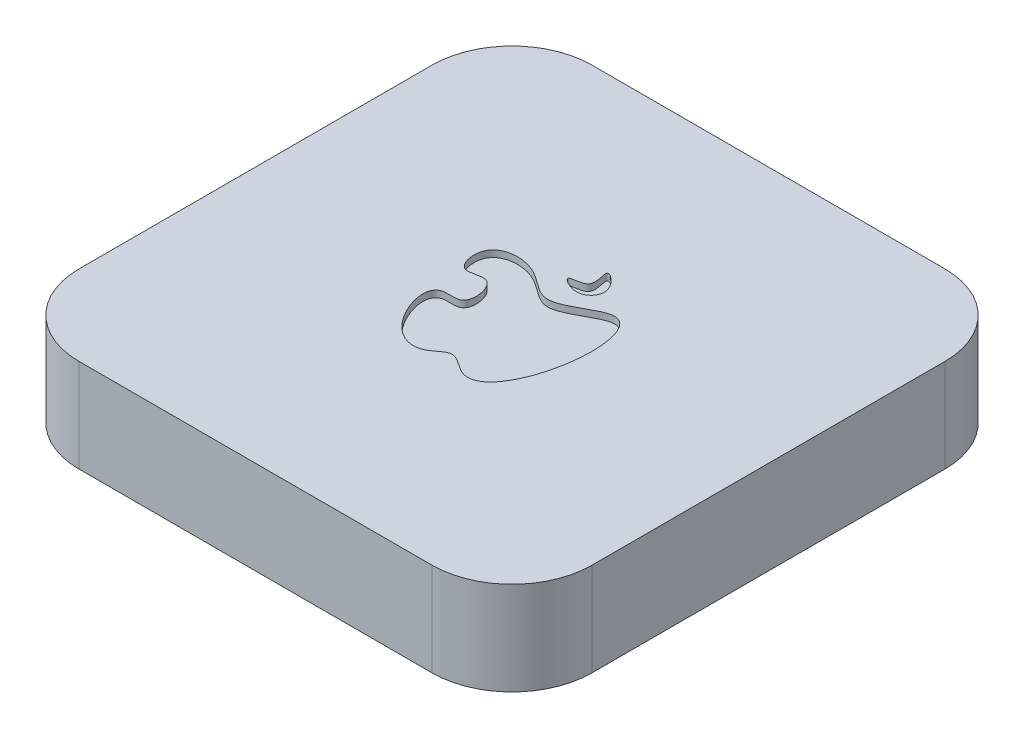
from build123d import *

# Parameters (mm, degrees)
BOSS_EXTRUDE1_DEPTH = 35.56
CUT_EXTRUDE1_DEPTH  = 2.54


with BuildPart() as part:
    # Sketch1 → Boss-Extrude1 (new body)
    with BuildSketch(Plane(origin=(0, 0, 0), x_dir=(1, 0, 0), z_dir=(0, 1, 0))):
        with BuildLine():
            Line((-67.31, -97.79), (67.31, -97.79))
            ThreePointArc((67.31, -97.79), (88.862614691, -88.862614691), (97.79, -67.31))
            Line((97.79, -67.31), (97.79, 67.31))
            ThreePointArc((97.79, 67.31), (88.862614691, 88.862614691), (67.31, 97.79))
            Line((67.31, 97.79), (-67.31, 97.79))
            ThreePointArc((-67.31, 97.79), (-88.862614691, 88.862614691), (-97.79, 67.31))
            Line((-97.79, 67.31), (-97.79, -67.31))
            ThreePointArc((-97.79, -67.31), (-88.862614691, -88.862614691), (-67.31, -97.79))
        make_face()
    extrude(amount=BOSS_EXTRUDE1_DEPTH)

    # Sketch2 → Cut-Extrude1 (cut)
    with BuildSketch(Plane(origin=(0, 35.56, 0), x_dir=(1, 0, 0), z_dir=(0, 1, 0))):
        with BuildLine():
            add(Edge.make_bspline(
                [(1.069159263, 12.053957352), (7.026900295, 11.625396007), (25.310862844, 29.234177767), (30.491031338, -7.916988095), (15.026759827, -36.109498005), (1.530770275, -21.83529591), (-6.040576613, -30.612635114), (-20.658401128, -26.846483994), (-28.267746675, -2.501714901), (-10.902260805, -7.058320175), (-14.044140154, 10.399607654), (-25.914455938, 3.072974608), (-29.507731033, 20.421135825), (-10.125556887, 21.796230615), (-3.363362348, 12.372804279), (1.069159263, 12.053957352)],
                knots=[0, 0, 0, 0, 0.107274199, 0.250434142, 0.395980258, 0.443398128, 0.47894856, 0.546712741, 0.653285311, 0.68880468, 0.749021257, 0.788585463, 0.841034552, 0.920188675, 1, 1, 1, 1], degree=3))
        make_face()
        with BuildLine():
            add(Edge.make_bspline(
                [(4.288165985, 31.968571753), (4.959875783, 32.927739875), (13.302817449, 26.054551709), (5.976088668, 17.468338472), (-5.163355857, 24.084090932), (7.583617977, 23.014813046), (3.679789011, 31.099839749), (4.288165985, 31.968571753)],
                knots=[0, 0, 0, 0, 0.21621725, 0.454945614, 0.634777537, 0.804169008, 1, 1, 1, 1], degree=3))
        make_face()
    extrude(amount=-CUT_EXTRUDE1_DEPTH, mode=Mode.SUBTRACT)


solid = part.part
